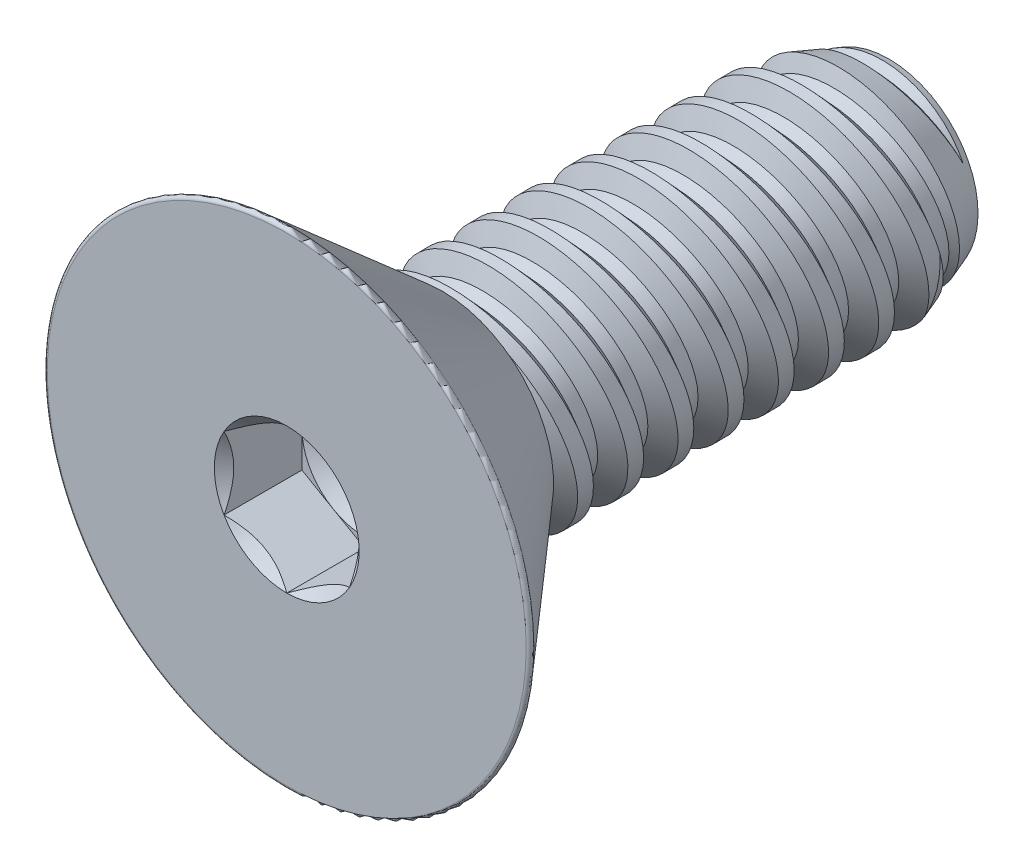
from build123d import *

# Parameters (mm, degrees)
SKETCH1_W          = 7.0612
SKETCH1_H          = 1.7526
LPATTERN1_COUNT    = 9
LPATTERN1_PITCH    = 0.79375
LPATTERN2_COUNT    = 2
LPATTERN2_PITCH    = 0.79375
SKETCH4_R          = 3.8989
EXTRUDE1_DEPTH     = 2.4638
FILLET1_R          = 0.0508
CUT_EXTRUDE1_DEPTH = 1.2319
SKETCH7_R          = 1.14567944
CUT_EXTRUDE4_DEPTH = 1.2319
CUT_EXTRUDE4_DRAFT = -45
SKETCH8_R          = 0.9921875
CUT_EXTRUDE5_DEPTH = 0.410633333
CUT_EXTRUDE5_TAPER = 60


with BuildPart() as part:
    # Sketch1 → Revolve1 (revolve)
    with BuildSketch(Plane(origin=(0, 0, 0), x_dir=(0, 0, -1), z_dir=(1, 0, 0))):
        with Locations((3.5306, 0.8763)):
            Rectangle(SKETCH1_W, SKETCH1_H)
    revolve(axis=Axis((0, 0, 0), (0, 0, 1)))

    # Sketch2 → Cut-Revolve1 (revolve, cut)
    with BuildSketch(Plane(origin=(0, 0, 0), x_dir=(0, 0, -1), z_dir=(1, 0, 0))):
        Polygon((0.096768654, 1.774513192), (0.774149232, 1.927905533), (0.6271145, 1.454101991), (0.433577192, 1.410275607), align=None)
    cut_revolve1 = revolve(axis=Axis((0, -0.193538035, 0), (0, 0.220857364, -0.975306119)), mode=Mode.SUBTRACT)

    # Sketch3 → Cut-Revolve2 (revolve, cut)
    with BuildSketch(Plane(origin=(0, 0, 0), x_dir=(0, 0, -1), z_dir=(1, 0, 0))):
        Polygon((7.0612, 1.410275607), (6.120671461, 1.7526), (7.0612, 1.7526), align=None)
    revolve(axis=Axis((0, 0, -6.120671461), (0, 0, 1)), mode=Mode.SUBTRACT)

    # LPattern1: Cut-Revolve1 ×9
    with Locations(*[(0, 0, -i * LPATTERN1_PITCH) for i in range(1, LPATTERN1_COUNT)]):
        add(cut_revolve1, mode=Mode.SUBTRACT)

    # LPattern2: Cut-Revolve1 ×2
    with Locations(*[(0, 0, i * LPATTERN2_PITCH) for i in range(1, LPATTERN2_COUNT)]):
        add(cut_revolve1, mode=Mode.SUBTRACT)

    # Sketch4 → Extrude1 (add)
    with BuildSketch(Plane.XY):
        Circle(SKETCH4_R)
    extrude(amount=EXTRUDE1_DEPTH)

    # Sketch9 → Cut-Revolve3 (revolve, cut)
    with BuildSketch(Plane(origin=(0, 0, 0), x_dir=(0, 0, -1), z_dir=(1, 0, 0))):
        Polygon((-2.4638, 3.8989), (0, 1.757151335), (0, 3.8989), align=None)
    revolve(axis=Axis((0, 0, 0), (0, 0, 1)), mode=Mode.SUBTRACT)

    # Fillet1
    fillet1_edges = [part.edges().sort_by_distance(p)[0] for p in [
        (0, -3.8989, 2.4638),
    ]]
    fillet(fillet1_edges, radius=FILLET1_R)

    # Sketch6 → Cut-Extrude1 (cut)
    with BuildSketch(Plane.XY.offset(2.4638)):
        Polygon((0, -1.14567944), (0.9921875, -0.57283972), (0.9921875, 0.57283972), (0, 1.14567944), (-0.9921875, 0.57283972), (-0.9921875, -0.57283972), align=None)
    extrude(amount=-CUT_EXTRUDE1_DEPTH, mode=Mode.SUBTRACT)


with BuildPart() as cut_extrude4_tool:
    # Sketch7 → Cut-Extrude4 (with draft: the straight prism first)
    with BuildSketch(Plane.XY.offset(2.4638)):
        Circle(SKETCH7_R)
    extrude(amount=-CUT_EXTRUDE4_DEPTH)
    # Cut-Extrude4: the draft: its side faces are tilted about the plane it starts from
    cut_extrude4_sides = [cut_extrude4_tool.faces().sort_by_distance(p)[0] for p in [
        (-1.14567944, 0, 1.84785),
    ]]
    draft(cut_extrude4_sides, Plane.XY.offset(2.4638), CUT_EXTRUDE4_DRAFT)


with BuildPart() as part_1:
    add(part.part)

    # Cut-Extrude4: cut by cut_extrude4_tool
    add(cut_extrude4_tool.part, mode=Mode.SUBTRACT)

    # Sketch8 → Cut-Extrude5 (cut)
    with BuildSketch(Plane.XY.offset(1.2319)):
        Circle(SKETCH8_R)
    extrude(amount=-CUT_EXTRUDE5_DEPTH, taper=CUT_EXTRUDE5_TAPER, mode=Mode.SUBTRACT)


solid = part_1.part
